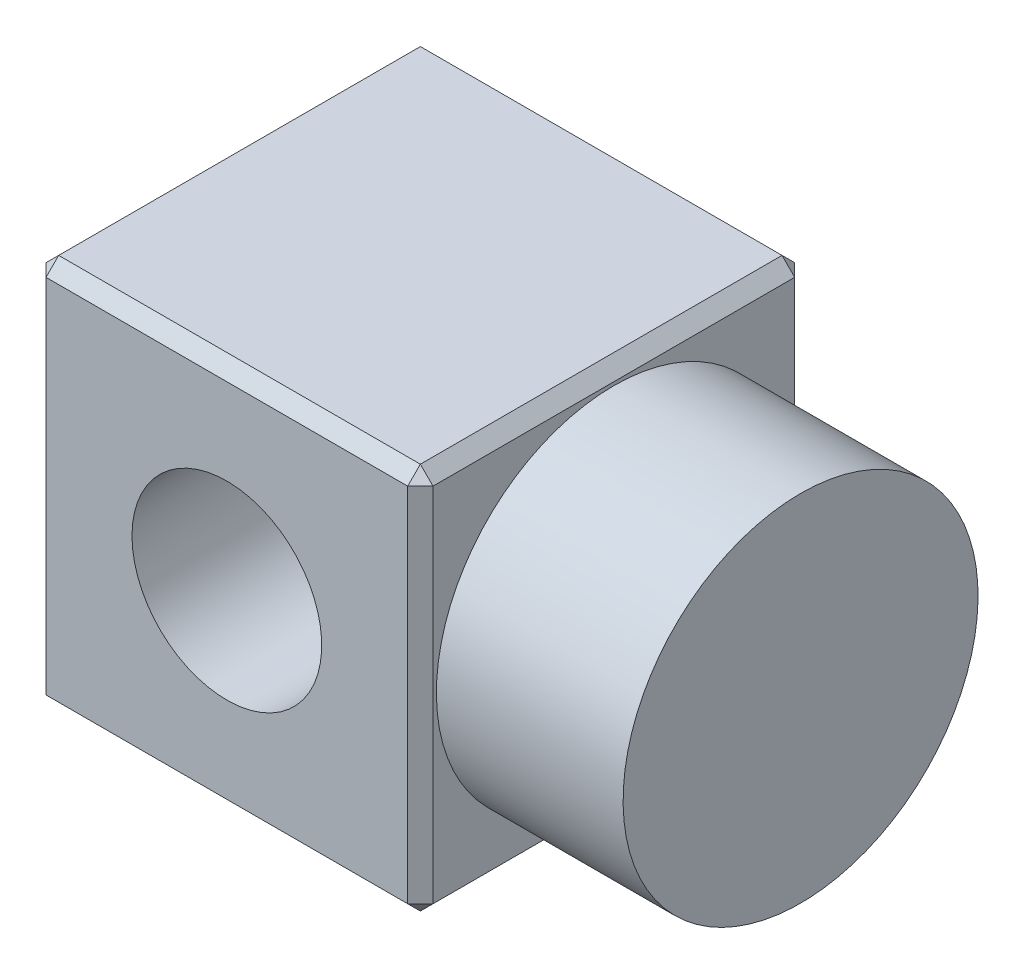
from build123d import *

# Parameters (mm, degrees)
SKETCH1_W           = 76.33
SKETCH1_H           = 76.33
BOSS_EXTRUDE1_DEPTH = 76.33
SKETCH2_R           = 35
BOSS_EXTRUDE2_DEPTH = 36.82
CHAMFER1_SIZE       = 2.5
CUT_EXTRUDE1_REACH  = 78.33
SKETCH3_R           = 18.71


with BuildPart() as part:
    # Sketch1 → Boss-Extrude1 (new body)
    with BuildSketch(Plane.ZY.offset(-1848.740517551)):
        Rectangle(SKETCH1_W, SKETCH1_H)
    extrude(amount=BOSS_EXTRUDE1_DEPTH)

    # Sketch2 → Boss-Extrude2 (add)
    with BuildSketch(Plane(origin=(1848.740517551, 0, 0), x_dir=(0, 0, -1), z_dir=(1, 0, 0))):
        Circle(SKETCH2_R)
    extrude(amount=BOSS_EXTRUDE2_DEPTH)

    # Chamfer1
    chamfer1_edges = [part.edges().sort_by_distance(p)[0] for p in [
        (1772.410517551, -38.165, 0),
        (1772.410517551, 0, -38.165),
        (1772.410517551, 38.165, 0),
        (1848.740517551, 0, -38.165),
        (1848.740517551, -38.165, 0),
        (1848.740517551, 0, 38.165),
        (1848.740517551, 38.165, 0),
        (1772.410517551, 0, 38.165),
        (1810.575517551, 38.165, -38.165),
        (1810.575517551, -38.165, -38.165),
        (1810.575517551, -38.165, 38.165),
        (1810.575517551, 38.165, 38.165),
    ]]
    chamfer(chamfer1_edges, length=CHAMFER1_SIZE)

    # Sketch3 → Cut-Extrude1 (cut, up to next)
    with BuildSketch(Plane(origin=(0, 0, -38.165), x_dir=(-1, 0, 0), z_dir=(0, 0, -1)), mode=Mode.PRIVATE) as cut_extrude1_sk1:
        with Locations((-1810.575517551, 0)):
            Circle(SKETCH3_R)
    cut_extrude1_tool1 = extrude(cut_extrude1_sk1.sketch, amount=-CUT_EXTRUDE1_REACH, mode=Mode.PRIVATE) & part.part
    add(cut_extrude1_tool1.solids().sort_by_distance((1810.575518, 0, -38.165))[0], mode=Mode.SUBTRACT)


solid = part.part
